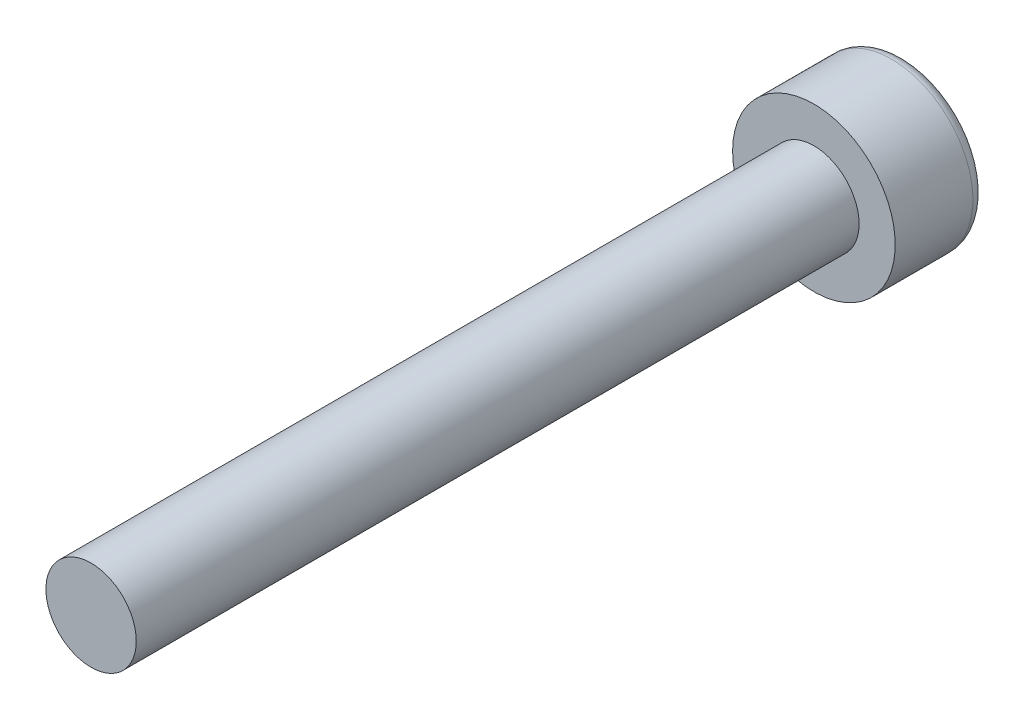
from build123d import *

# Parameters (mm, degrees)
CROQUIS1_R              = 1.25
SALIENTE_EXTRUIR1_DEPTH = 20
CROQUIS2_R              = 2.25
SALIENTE_EXTRUIR2_DEPTH = 2.5
CORTAR_EXTRUIR1_DEPTH   = 1.5
REDONDEO1_R             = 0.35


with BuildPart() as part:
    # Croquis1 → Saliente-Extruir1 (new body)
    with BuildSketch(Plane.XY):
        Circle(CROQUIS1_R)
    extrude(amount=SALIENTE_EXTRUIR1_DEPTH)

    # Croquis2 → Saliente-Extruir2 (add)
    with BuildSketch(Plane(origin=(0, 0, 0), x_dir=(-1, 0, 0), z_dir=(0, 0, -1))):
        Circle(CROQUIS2_R)
    extrude(amount=SALIENTE_EXTRUIR2_DEPTH)

    # Croquis3 → Cortar-Extruir1 (cut)
    with BuildSketch(Plane(origin=(0, 0, -2.5), x_dir=(-1, 0, 0), z_dir=(0, 0, -1))):
        Polygon((0, -1.154700538), (1, -0.577350269), (1, 0.577350269), (0, 1.154700538), (-1, 0.577350269), (-1, -0.577350269), align=None)
    extrude(amount=-CORTAR_EXTRUIR1_DEPTH, mode=Mode.SUBTRACT)

    # Redondeo1
    redondeo1_edges = [part.edges().sort_by_distance(p)[0] for p in [
        (2.25, 0, -2.5),
    ]]
    fillet(redondeo1_edges, radius=REDONDEO1_R)


solid = part.part
